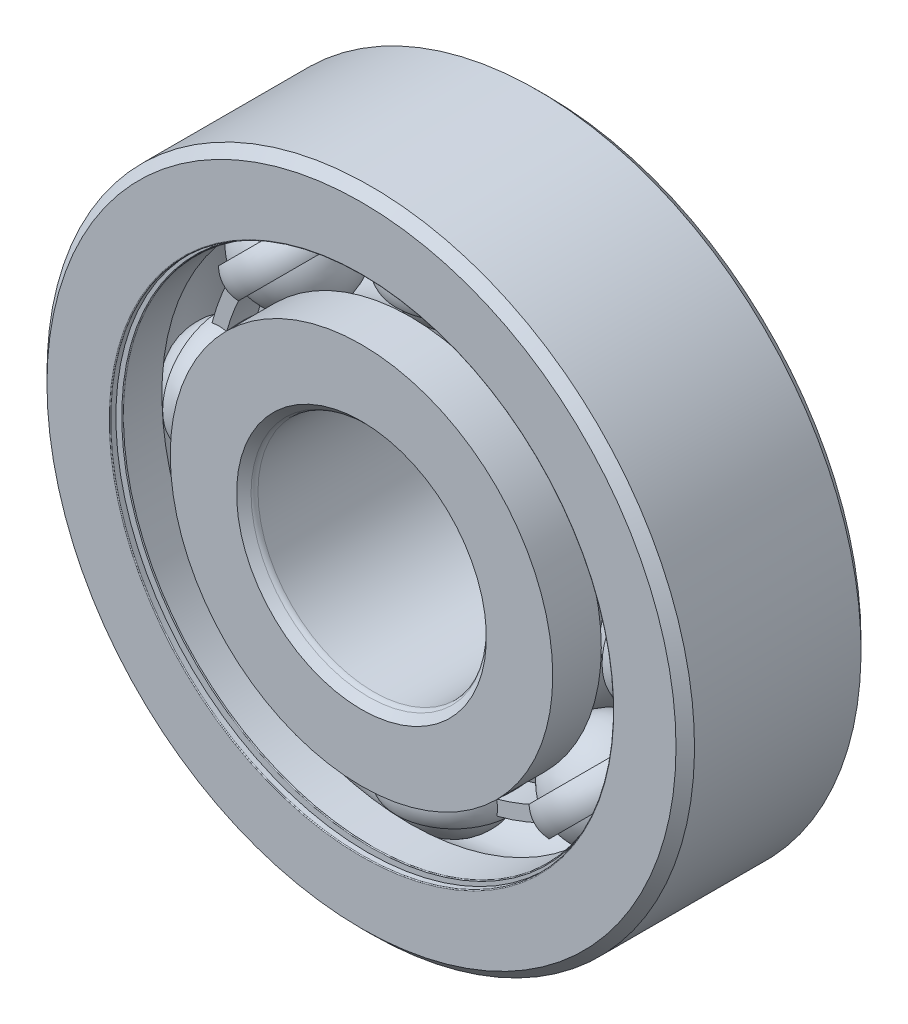
from build123d import *

# Parameters (mm, degrees)
BOSS_EXTRUDE1_DEPTH = 0.666666667
CIRPATTERN1_COUNT   = 8
CIRPATTERN2_COUNT   = 8
FILLET1_R           = 0.036
FILLET2_R           = 0.3


with BuildPart() as part:
    # Sketch3 → Revolve1 (revolve)
    with BuildSketch(Plane(origin=(0, 0, 0), x_dir=(0, 0, -1), z_dir=(1, 0, 0))):
        with BuildLine():
            Line((3.6, 14), (4, 13.6))
            Line((4, 13.6), (4, 10.730769231))
            Line((4, 10.730769231), (1.9, 10.730769231))
            ThreePointArc((1.9, 10.730769231), (0, 11.763800543), (-1.9, 10.730769231))
            Line((-1.9, 10.730769231), (-4, 10.730769231))
            Line((-4, 10.730769231), (-4, 13.6))
            Line((-4, 13.6), (-3.6, 14))
            Line((-3.6, 14), (3.6, 14))
        make_face()
    revolve(axis=Axis((0, 0, 4), (0, 0, -1)))

    # Sketch8 → Cut-Revolve1 (revolve, cut)
    with BuildSketch(Plane(origin=(0, 0, 0), x_dir=(0, 0, -1), z_dir=(1, 0, 0))):
        Polygon((-3.744, 10.730769231), (-3.6, 10.730769231), (-3.6, 11.820512821), (-3.744, 11.820512821), (-3.744, 10.874769231), (-4, 10.874769231), (-4, 10.730769231), align=None)
        Polygon((3.6, 10.730769231), (3.744, 10.730769231), (4, 10.730769231), (4, 10.874769231), (3.744, 10.874769231), (3.744, 11.820512821), (3.6, 11.820512821), align=None)
    revolve(axis=Axis((0, 0, 4), (0, 0, -1)), mode=Mode.SUBTRACT)

    # Fillet1
    fillet1_edges = [part.edges().sort_by_distance(p)[0] for p in [
        (0, -10.730769231, -3.6),
        (0, -10.874769231, -4),
        (0, -10.730769231, 3.6),
        (0, -10.874769231, 4),
    ]]
    fillet(fillet1_edges, radius=FILLET1_R)


with BuildPart() as body_2:
    # Sketch4 → Revolve2 (revolve)
    with BuildSketch(Plane(origin=(0, 0, 0), x_dir=(0, 0, -1), z_dir=(1, 0, 0))):
        with BuildLine():
            Line((-3.6, 5), (-4, 5.4))
            Line((-4, 5.4), (-4, 8.269230769))
            Line((-4, 8.269230769), (-1.9, 8.269230769))
            ThreePointArc((-1.9, 8.269230769), (0, 7.236199457), (1.9, 8.269230769))
            Line((1.9, 8.269230769), (4, 8.269230769))
            Line((4, 8.269230769), (4, 5.4))
            Line((4, 5.4), (3.6, 5))
            Line((3.6, 5), (-3.6, 5))
        make_face()
    revolve(axis=Axis((0, 0, 4), (0, 0, -1)))

    # Fillet2
    fillet2_edges = [body_2.edges().sort_by_distance(p)[0] for p in [
        (0, -5, -3.6),
        (0, -5, 3.6),
    ]]
    fillet(fillet2_edges, radius=FILLET2_R)


with BuildPart() as body_3:
    # Sketch5 → Revolve3 (revolve)
    with BuildSketch(Plane(origin=(0, 0, 0), x_dir=(0, 0, -1), z_dir=(1, 0, 0))):
        with BuildLine():
            Line((-2.263800543, 9.5), (2.263800543, 9.5))
            ThreePointArc((2.263800543, 9.5), (0, 11.763800543), (-2.263800543, 9.5))
        make_face()
    revolve(axis=Axis((0, 9.5, 2.263800543), (0, 0, -1)))


with BuildPart() as body_4:
    # Sketch6 → Revolve4 (revolve)
    with BuildSketch(Plane(origin=(0, 0, 0), x_dir=(0, 0, -1), z_dir=(1, 0, 0))):
        with BuildLine():
            Line((-2.178553344, 10.115384615), (-2.482127787, 10.115384615))
            ThreePointArc((-2.482127787, 10.115384615), (-2.633915008, 9.5), (-2.482127787, 8.884615385))
            Line((-2.482127787, 8.884615385), (-2.178553344, 8.884615385))
            ThreePointArc((-2.178553344, 8.884615385), (-2.263800543, 9.5), (-2.178553344, 10.115384615))
        make_face()
    revolve4 = revolve(axis=Axis((0, 14, 0), (0, -1, 0)))

    # Sketch7 → Boss-Extrude1 (add, symmetric)
    with BuildSketch(Plane.XY):
        with BuildLine():
            Line((6.717514421, 6.717514421), (7.152657056, 7.152657056))
            ThreePointArc((7.152657056, 7.152657056), (3.870990104, 9.34539681), (0, 10.115384615))
            Line((0, 10.115384615), (0, 9.5))
            ThreePointArc((0, 9.5), (3.635492607, 8.776855559), (6.717514421, 6.717514421))
        make_face()
    boss_extrude1 = extrude(amount=BOSS_EXTRUDE1_DEPTH, both=True)

    # CirPattern2: Revolve4, Boss-Extrude1 ×8 about axis
    cirpattern2_axis = Axis((0, 0, 4), (0, 0, -1))
    add([revolve4.rotate(cirpattern2_axis, i * 360 / CIRPATTERN2_COUNT) for i in range(1, CIRPATTERN2_COUNT)])
    add([boss_extrude1.rotate(cirpattern2_axis, i * 360 / CIRPATTERN2_COUNT) for i in range(1, CIRPATTERN2_COUNT)])


with BuildPart() as cirpattern1_1:
    # CirPattern1: pattern copy
    add(body_3.part.rotate(Axis((0, 0, 4), (0, 0, -1)), 1 * 360 / CIRPATTERN1_COUNT))


with BuildPart() as cirpattern1_2:
    # CirPattern1: pattern copy
    add(body_3.part.rotate(Axis((0, 0, 4), (0, 0, -1)), 2 * 360 / CIRPATTERN1_COUNT))


with BuildPart() as cirpattern1_3:
    # CirPattern1: pattern copy
    add(body_3.part.rotate(Axis((0, 0, 4), (0, 0, -1)), 3 * 360 / CIRPATTERN1_COUNT))


with BuildPart() as cirpattern1_4:
    # CirPattern1: pattern copy
    add(body_3.part.rotate(Axis((0, 0, 4), (0, 0, -1)), 4 * 360 / CIRPATTERN1_COUNT))


with BuildPart() as cirpattern1_5:
    # CirPattern1: pattern copy
    add(body_3.part.rotate(Axis((0, 0, 4), (0, 0, -1)), 5 * 360 / CIRPATTERN1_COUNT))


with BuildPart() as cirpattern1_6:
    # CirPattern1: pattern copy
    add(body_3.part.rotate(Axis((0, 0, 4), (0, 0, -1)), 6 * 360 / CIRPATTERN1_COUNT))


with BuildPart() as cirpattern1_7:
    # CirPattern1: pattern copy
    add(body_3.part.rotate(Axis((0, 0, 4), (0, 0, -1)), 7 * 360 / CIRPATTERN1_COUNT))


solid = Compound([part.part, body_2.part, body_3.part, body_4.part, cirpattern1_1.part, cirpattern1_2.part, cirpattern1_3.part, cirpattern1_4.part, cirpattern1_5.part, cirpattern1_6.part, cirpattern1_7.part])
